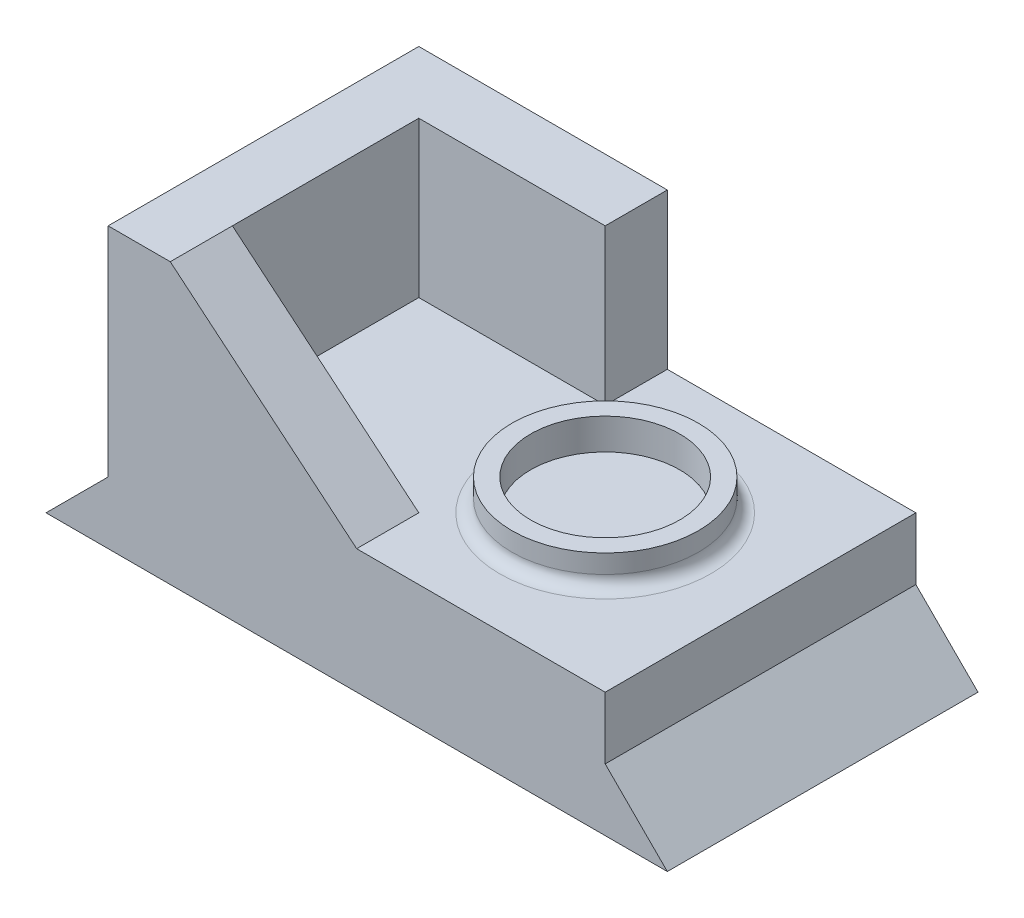
from build123d import *

# Parameters (mm, degrees)
BOSS_EXTRU_3_DEPTH = 50
ESQUISSE3_W        = 80
ESQUISSE3_H        = 10
BOSS_EXTRU_4_DEPTH = 50
ESQUISSE4_R        = 15
ESQUISSE4_R_2      = 12
BOSS_EXTRU_5_DEPTH = 5
CONG_1_R           = 2
BOSS_EXTRU_6_DEPTH = 25
BOSS_EXTRU_7_DEPTH = 10


with BuildPart() as part:
    # Esquisse2 → Boss.-Extru.3 (new body)
    with BuildSketch(Plane.XY):
        Polygon((0, 0), (100, 0), (90, 10), (10, 10), align=None)
    extrude(amount=BOSS_EXTRU_3_DEPTH)

    # Esquisse3 → Boss.-Extru.4 (add)
    with BuildSketch(Plane.XY.offset(50)):
        with Locations((50, 15)):
            Rectangle(ESQUISSE3_W, ESQUISSE3_H)
    extrude(amount=-BOSS_EXTRU_4_DEPTH)

    # Esquisse4 → Boss.-Extru.5 (add)
    with BuildSketch(Plane(origin=(0, 20, 0), x_dir=(1, 0, 0), z_dir=(0, 1, 0))):
        with Locations((65, -25)):
            Circle(ESQUISSE4_R)
        with Locations((65, -25)):
            Circle(ESQUISSE4_R_2, mode=Mode.SUBTRACT)
    extrude(amount=BOSS_EXTRU_5_DEPTH)

    # Congé1
    cong_1_edges = [part.edges().sort_by_distance(p)[0] for p in [
        (50, 20, 25),
    ]]
    fillet(cong_1_edges, radius=CONG_1_R)

    # Esquisse5 → Boss.-Extru.6 (add)
    with BuildSketch(Plane(origin=(0, 20, 0), x_dir=(1, 0, 0), z_dir=(0, 1, 0))):
        Polygon((20, 0), (10, 0), (10, -50), (20, -50), (20, -10), (50, -10), (50, 0), align=None)
    extrude(amount=BOSS_EXTRU_6_DEPTH)

    # Esquisse6 → Boss.-Extru.7 (add)
    with BuildSketch(Plane.XY.offset(50)):
        Polygon((20, 45), (50, 20), (20, 20), align=None)
    extrude(amount=-BOSS_EXTRU_7_DEPTH)


solid = part.part
